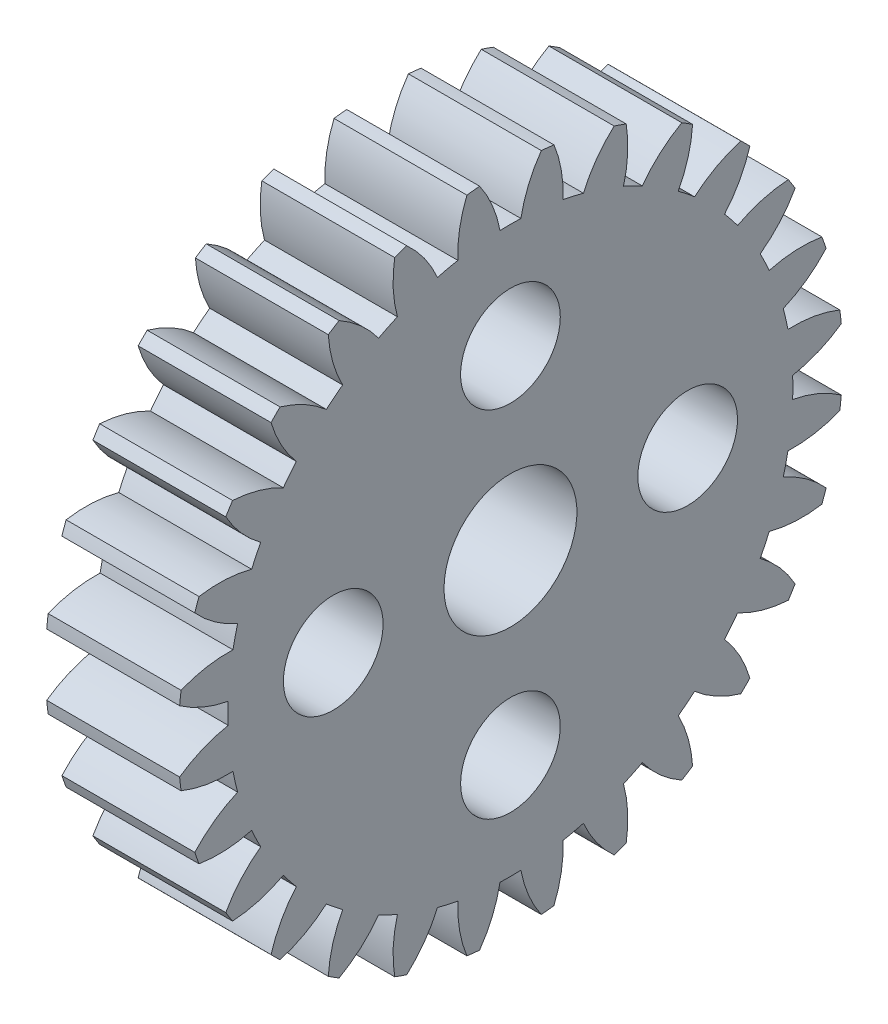
from build123d import *

# Parameters (mm, degrees)
BASPROSKE_W          = 6
BASPROSKE_H          = 15
TOOTHCUT_DEPTH       = 23.045407685
TEETHCUTS_COUNT      = 28
TEETHCUTS_ANGLE      = 347.142857143
BORSKE_R             = 3
BORE_DEPTH           = 50.0000508
M4_CLEARANCE_HOLE1_D = 4.5
CIRPATTERN1_COUNT    = 4


with BuildPart() as part:
    # BasProSke → Base-Revolve (revolve)
    with BuildSketch(Plane(origin=(0, 0, 0), x_dir=(1, 0, 0), z_dir=(0, 1, 0)), mode=Mode.PRIVATE) as base_revolve_sk:
        with Locations((3, 7.5)):
            Rectangle(BASPROSKE_W, BASPROSKE_H)
    revolve(base_revolve_sk.sketch.rotate(Axis((-10, 0, 0), (1, 0, 0)), 180), axis=Axis((-10, 0, 0), (1, 0, 0)))

    # TooCutSke → ToothCut (cut, through all)
    with BuildSketch(Plane(origin=(0, 0, 0), x_dir=(0, 0, -1), z_dir=(1, 0, 0))):
        with BuildLine():
            ThreePointArc((0.471336039, 12.740284272), (0, 12.749), (-0.471336039, 12.740284272))
            ThreePointArc((-0.471336039, 12.740284272), (-0.81983923, 13.900763331), (-1.409805137, 14.959114099))
            ThreePointArc((-1.409805137, 14.959114099), (0, 15.0254), (1.409805137, 14.959114099))
            ThreePointArc((1.409805137, 14.959114099), (0.81983923, 13.900763331), (0.471336039, 12.740284272))
        make_face()
    toothcut = extrude(amount=TOOTHCUT_DEPTH, mode=Mode.SUBTRACT)

    # TeethCuts: ToothCut ×28 about axis
    teethcuts_axis = Axis((-10, 0, 0), (1, 0, 0))
    for i in range(1, TEETHCUTS_COUNT):
        add(toothcut.rotate(teethcuts_axis, i * TEETHCUTS_ANGLE / (TEETHCUTS_COUNT - 1)), mode=Mode.SUBTRACT)

    # BorSke → Bore (cut, symmetric)
    with BuildSketch(Plane(origin=(0, 0, 0), x_dir=(0, 0, -1), z_dir=(1, 0, 0))):
        with Locations(Location((0, 0, 0), (0, 0, 180))):
            Circle(BORSKE_R)
    extrude(amount=BORE_DEPTH, both=True, mode=Mode.SUBTRACT)

    # M4 Clearance Hole1 (through all)
    with Locations(Plane(origin=(6, 0, 0), x_dir=(0, 0, -1), z_dir=(1, 0, 0))):
        with Locations((0, 8)):
            m4_clearance_hole1 = Hole(M4_CLEARANCE_HOLE1_D / 2)

    # CirPattern1: M4 Clearance Hole1 ×4 about axis
    cirpattern1_axis = Axis((0, 0, 0), (1, 0, 0))
    for i in range(1, CIRPATTERN1_COUNT):
        add(m4_clearance_hole1.rotate(cirpattern1_axis, i * 360 / CIRPATTERN1_COUNT), mode=Mode.SUBTRACT)


solid = part.part
